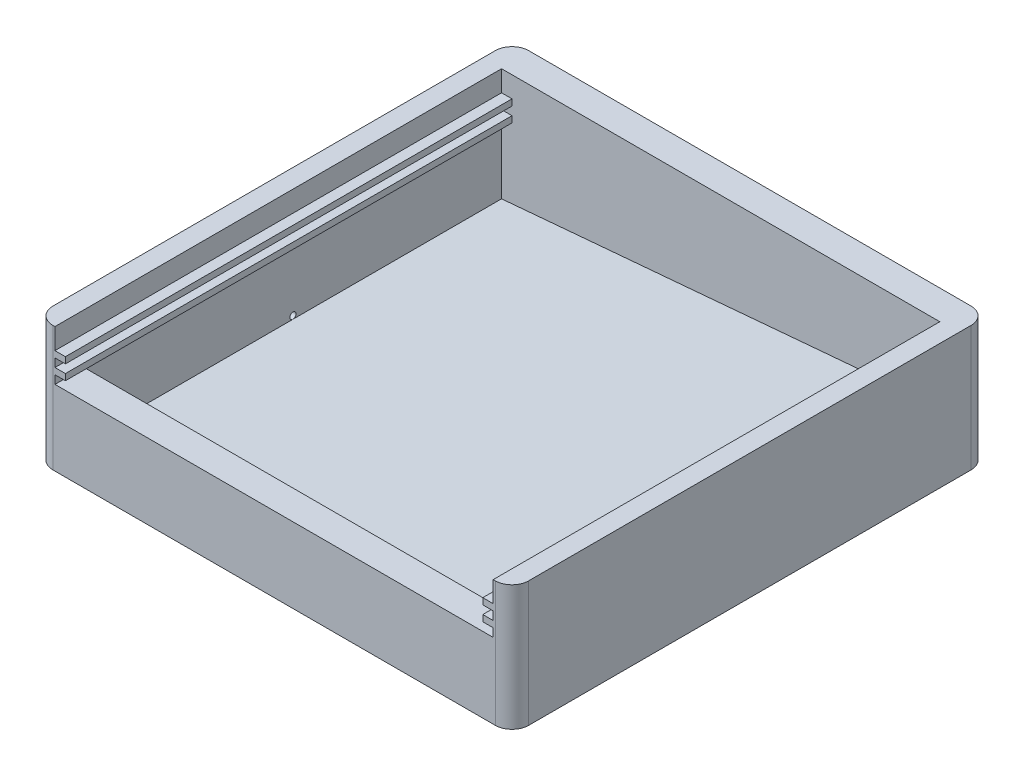
from build123d import *

# Parameters (mm, degrees)
CROQUIS1_W                          = 114
CROQUIS1_H                          = 114
SALIENTE_EXTRUIR1_DEPTH             = 30
REDONDEO1_R                         = 4
CROQUIS2_W                          = 105
CROQUIS2_H                          = 100
CORTAR_EXTRUIR1_DEPTH               = 27
CROQUIS3_W                          = 105
CROQUIS3_H                          = 12
CORTAR_EXTRUIR2_DEPTH               = 7
CROQUIS5_W                          = 2.5
CROQUIS5_H                          = 1.5
SALIENTE_EXTRUIR2_DEPTH             = 107
SALIENTE_EXTRUIR3_REACH             = 59
SALIENTE_EXTRUIR3_DIRECTION_2_REACH = 59
CROQUIS7_R                          = 0.75
CORTAR_EXTRUIR3_DEPTH               = 4.5


with BuildPart() as part:
    # Croquis1 → Saliente-Extruir1 (new body)
    with BuildSketch(Plane(origin=(0, 0, 0), x_dir=(1, 0, 0), z_dir=(0, 1, 0))):
        Rectangle(CROQUIS1_W, CROQUIS1_H)
    extrude(amount=SALIENTE_EXTRUIR1_DEPTH)

    # Redondeo1
    redondeo1_edges = [part.edges().sort_by_distance(p)[0] for p in [
        (57, 15, 57),
        (-57, 15, 57),
        (-57, 15, -57),
        (57, 15, -57),
    ]]
    fillet(redondeo1_edges, radius=REDONDEO1_R)

    # Croquis2 → Cortar-Extruir1 (cut)
    with BuildSketch(Plane(origin=(0, 30, 0), x_dir=(1, 0, 0), z_dir=(0, 1, 0))):
        Rectangle(CROQUIS2_W, CROQUIS2_H)
    extrude(amount=-CORTAR_EXTRUIR1_DEPTH, mode=Mode.SUBTRACT)

    # Croquis3 → Cortar-Extruir2 (cut)
    with BuildSketch(Plane.XY.offset(57)):
        with Locations((0, 24)):
            Rectangle(CROQUIS3_W, CROQUIS3_H)
    extrude(amount=-CORTAR_EXTRUIR2_DEPTH, mode=Mode.SUBTRACT)

    # Croquis5 → Saliente-Extruir2 (add)
    with BuildSketch(Plane.XY.offset(57)):
        with Locations((-51.25, 20.75)):
            Rectangle(CROQUIS5_W, CROQUIS5_H)
        with Locations((-51.25, 24.25)):
            Rectangle(CROQUIS5_W, CROQUIS5_H)
        with Locations((51.25, 20.75)):
            Rectangle(CROQUIS5_W, CROQUIS5_H)
        with Locations((51.25, 24.25)):
            Rectangle(CROQUIS5_W, CROQUIS5_H)
    extrude(amount=-SALIENTE_EXTRUIR2_DEPTH)

    # Saliente-Extruir3: up to this face of the body (flat: up to its plane)
    saliente_extruir3_end = Plane(part.part.faces().sort_by_distance((0, 16.468085106, -50))[0])
    # Croquis6 → Saliente-Extruir3 (add, up to the picked face)
    with BuildSketch(Plane.XY, mode=Mode.PRIVATE) as saliente_extruir3_sk1:
        Polygon((-52.5, 3), (52.5, 12.18630967), (52.5, 3), align=None)
    saliente_extruir3_tool1 = split(extrude(saliente_extruir3_sk1.sketch, amount=-SALIENTE_EXTRUIR3_REACH, mode=Mode.PRIVATE), bisect_by=saliente_extruir3_end, keep=Keep.BOTH, mode=Mode.PRIVATE)
    add(saliente_extruir3_tool1.solids().sort_by_distance((17.5, 6.062103, 0))[0])

    # Saliente-Extruir3 direction 2: up to this face of the body (flat: up to its plane)
    saliente_extruir3_direction_2_end = Plane(part.part.faces().sort_by_distance((0, 10.5, 50))[0])
    # Croquis6 → Saliente-Extruir3 direction 2 (add, up to the picked face)
    with BuildSketch(Plane.XY, mode=Mode.PRIVATE) as saliente_extruir3_direction_2_sk1:
        Polygon((-52.5, 3), (52.5, 12.18630967), (52.5, 3), align=None)
    saliente_extruir3_direction_2_tool1 = split(extrude(saliente_extruir3_direction_2_sk1.sketch, amount=SALIENTE_EXTRUIR3_DIRECTION_2_REACH, mode=Mode.PRIVATE), bisect_by=saliente_extruir3_direction_2_end, keep=Keep.BOTH, mode=Mode.PRIVATE)
    add(saliente_extruir3_direction_2_tool1.solids().sort_by_distance((17.5, 6.062103, 0))[0])

    # Croquis7 → Cortar-Extruir3 (cut)
    with BuildSketch(Plane.ZY.offset(57)):
        with Locations((0, 3.75)):
            Circle(CROQUIS7_R)
    extrude(amount=-CORTAR_EXTRUIR3_DEPTH, mode=Mode.SUBTRACT)

    # Croquis10 → Revolución1 (revolve)
    with BuildSketch(Plane.XY):
        Polygon((-57, 3), (-62, 3), (-62, 2.75), (-59, 2.2), (-59, 2.45), (-57, 2.45), align=None)
    revolve(axis=Axis((-57, 3.75, 0), (1, 0, 0)))


solid = part.part
